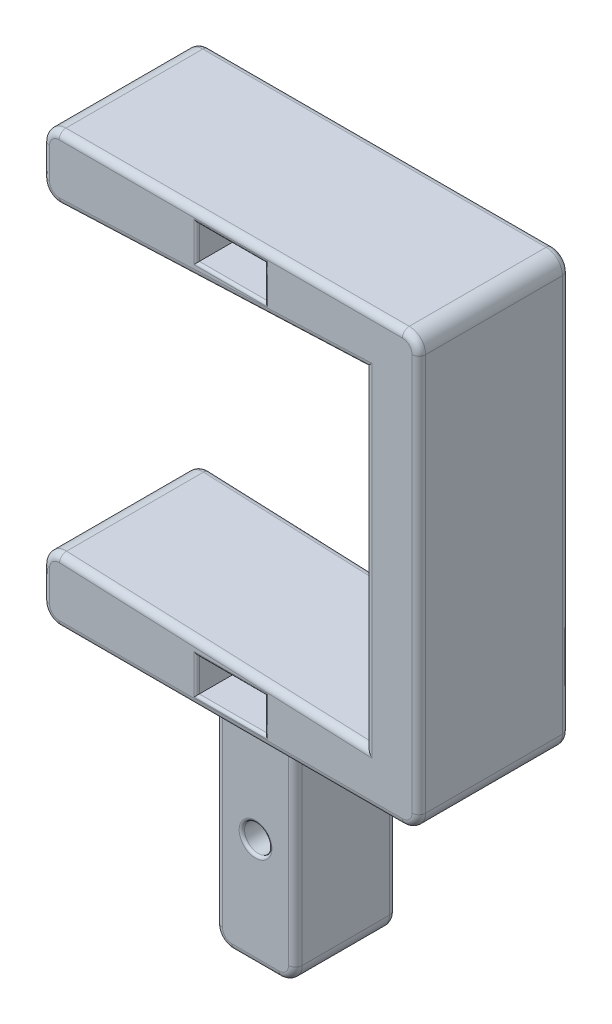
from build123d import *

# Parameters (mm, degrees)
BOSS_EXTRUDE1_DEPTH      = 7
BOSS_EXTRUDE1_DEPTH_BACK = 7
SKETCH2_R                = 1.27
BOSS_EXTRUDE2_DEPTH      = 4.699
BOSS_EXTRUDE2_DEPTH_BACK = 4.699
FILLET2_R                = 0.635
SKETCH3_W                = 6.35
SKETCH3_H                = 3.175
CUT_EXTRUDE1_DEPTH       = 8.0000001
CUT_EXTRUDE1_DEPTH_BACK  = 8.0000001
FILLET3_R                = 0.254


with BuildPart() as part:
    # Sketch1 → Boss-Extrude1 (new body, two sides)
    with BuildSketch(Plane.XY) as boss_extrude1_sk:
        with BuildLine():
            Line((-33.476, 40), (-1.524, 40))
            ThreePointArc((-1.524, 40), (-0.446369265, 39.553630735), (0, 38.476))
            Line((0, 38.476), (0, 1.524))
            ThreePointArc((0, 1.524), (-0.446369265, 0.446369265), (-1.524, 0))
            Line((-1.524, 0), (-33.476, 0))
            ThreePointArc((-33.476, 0), (-34.553630735, 0.446369265), (-35, 1.524))
            Line((-35, 1.524), (-35, 4.411177657))
            ThreePointArc((-35, 4.411177657), (-34.530961112, 5.51101085), (-33.41255505, 5.93385646))
            Line((-33.41255505, 5.93385646), (-5, 4.75))
            Line((-5, 4.75), (-5, 35.25))
            Line((-5, 35.25), (-33.41255505, 34.06614354))
            ThreePointArc((-33.41255505, 34.06614354), (-34.530961112, 34.48898915), (-35, 35.588822343))
            Line((-35, 35.588822343), (-35, 38.476))
            ThreePointArc((-35, 38.476), (-34.553630735, 39.553630735), (-33.476, 40))
        make_face()
    extrude(amount=BOSS_EXTRUDE1_DEPTH)
    extrude(boss_extrude1_sk.sketch, amount=-BOSS_EXTRUDE1_DEPTH_BACK)

    # Sketch2 → Boss-Extrude2 (add, two sides)
    with BuildSketch(Plane.XY) as boss_extrude2_sk:
        with BuildLine():
            Line((-21.21475, 0), (-13.78525, 0))
            Line((-13.78525, 0), (-13.78525, -18.796))
            ThreePointArc((-13.78525, -18.796), (-14.231619265, -19.873630735), (-15.30925, -20.32))
            Line((-15.30925, -20.32), (-19.69075, -20.32))
            ThreePointArc((-19.69075, -20.32), (-20.768380735, -19.873630735), (-21.21475, -18.796))
            Line((-21.21475, -18.796), (-21.21475, 0))
        make_face()
        with Locations((-17.5, -10.16)):
            Circle(SKETCH2_R, mode=Mode.SUBTRACT)
    extrude(amount=BOSS_EXTRUDE2_DEPTH)
    extrude(boss_extrude2_sk.sketch, amount=-BOSS_EXTRUDE2_DEPTH_BACK)

    # Fillet2
    fillet2_edges = [part.edges().sort_by_distance(p)[0] for p in [
        (-35, 37.032411171, -7),
        (-34.530961112, 34.48898915, -7),
        (-19.206277525, 34.65807177, -7),
        (-5, 20, -7),
        (-19.206277525, 5.34192823, -7),
        (-34.530961112, 5.51101085, -7),
        (-17.5, 40, 7),
        (-34.530961112, 34.48898915, 7),
        (-19.206277525, 34.65807177, 7),
        (-35, 2.967588829, -7),
        (-34.553630735, 0.446369265, -7),
        (-34.553630735, 39.553630735, 7),
        (-35, 37.032411171, 7),
        (-5, 20, 7),
        (-19.206277525, 5.34192823, 7),
        (-34.530961112, 5.51101085, 7),
        (-35, 2.967588829, 7),
        (-34.553630735, 0.446369265, 7),
        (-17.5, 0, 7),
        (-17.5, 0, -7),
        (-0.446369265, 0.446369265, 7),
        (0, 20, 7),
        (-0.446369265, 39.553630735, 7),
        (-17.5, 40, -7),
        (-0.446369265, 0.446369265, -7),
        (0, 20, -7),
        (-0.446369265, 39.553630735, -7),
        (-21.21475, -9.398, -4.699),
        (-13.78525, -9.398, -4.699),
        (-14.231619265, -19.873630735, -4.699),
        (-17.5, -20.32, -4.699),
        (-20.768380735, -19.873630735, -4.699),
        (-21.21475, -9.398, 4.699),
        (-20.768380735, -19.873630735, 4.699),
        (-17.5, -20.32, 4.699),
        (-14.231619265, -19.873630735, 4.699),
        (-13.78525, -9.398, 4.699),
        (-34.553630735, 39.553630735, -7),
    ]]
    fillet(fillet2_edges, radius=FILLET2_R)

    # Sketch3 → Cut-Extrude1 (cut, two sides)
    with BuildSketch(Plane.XY) as cut_extrude1_sk:
        with Locations((-17.5, 2.569270833)):
            Rectangle(SKETCH3_W, SKETCH3_H)
        with Locations((-17.5, 37.430729167)):
            Rectangle(SKETCH3_W, SKETCH3_H)
    extrude(amount=CUT_EXTRUDE1_DEPTH, mode=Mode.SUBTRACT)
    extrude(cut_extrude1_sk.sketch, amount=-CUT_EXTRUDE1_DEPTH_BACK, mode=Mode.SUBTRACT)

    # Fillet3
    fillet3_edges = [part.edges().sort_by_distance(p)[0] for p in [
        (-14.325, 2.569270833, -7),
        (-17.5, 0.981770833, -7),
        (-20.675, 2.569270833, -7),
        (-17.5, 4.156770833, -7),
        (-14.325, 2.569270833, 7),
        (-17.5, 4.156770833, 7),
        (-20.675, 2.569270833, 7),
        (-17.5, 0.981770833, 7),
        (-20.675, 37.430729167, -7),
        (-17.5, 39.018229167, -7),
        (-14.325, 37.430729167, -7),
        (-17.5, 35.843229167, -7),
        (-20.675, 37.430729167, 7),
        (-17.5, 35.843229167, 7),
        (-14.325, 37.430729167, 7),
        (-17.5, 39.018229167, 7),
        (-18.77, -10.16, -4.699),
        (-18.77, -10.16, 4.699),
    ]]
    fillet(fillet3_edges, radius=FILLET3_R)


solid = part.part
